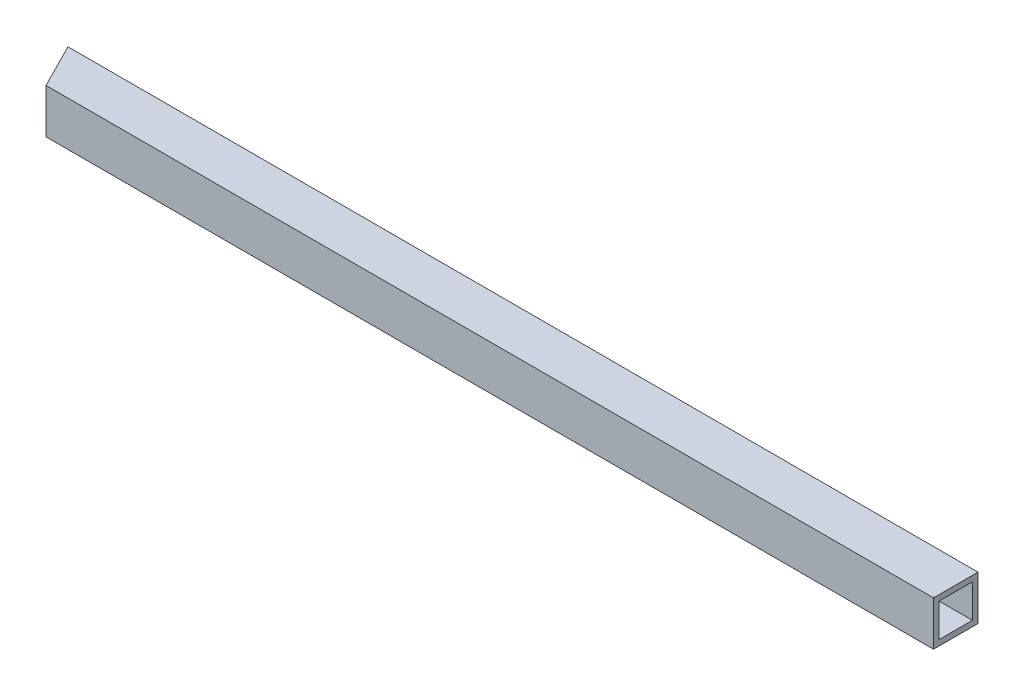
from build123d import *

# Parameters (mm, degrees)
SKETCH2_W               = 4155.694
SKETCH2_H               = 203.2
BOSS_EXTRUDE1_DEPTH     = 203.2
SKETCH3_W               = 152.4
SKETCH3_H               = 152.4
CUT_EXTRUDE1_DEPTH      = 1
CUT_EXTRUDE1_DEPTH_BACK = 4156.694
CUT_EXTRUDE2_DEPTH      = 1
CUT_EXTRUDE2_DEPTH_BACK = 204.2


with BuildPart() as part:
    # Sketch2 → Boss-Extrude1 (new body)
    with BuildSketch(Plane.XY):
        with Locations((2077.847, 101.6)):
            Rectangle(SKETCH2_W, SKETCH2_H)
    extrude(amount=BOSS_EXTRUDE1_DEPTH)

    # Sketch3 → Cut-Extrude1 (cut, two sides)
    with BuildSketch(Plane.ZY) as cut_extrude1_sk:
        with Locations((101.6, 101.6)):
            Rectangle(SKETCH3_W, SKETCH3_H)
    extrude(amount=CUT_EXTRUDE1_DEPTH, mode=Mode.SUBTRACT)
    extrude(cut_extrude1_sk.sketch, amount=-CUT_EXTRUDE1_DEPTH_BACK, mode=Mode.SUBTRACT)

    # Sketch4 → Cut-Extrude2 (cut, two sides)
    with BuildSketch(Plane(origin=(0, 203.2, 0), x_dir=(1, 0, 0), z_dir=(0, 1, 0))) as cut_extrude2_sk:
        Polygon((0, 0), (102.866376443, -203.2), (0, -203.2), align=None)
    extrude(amount=CUT_EXTRUDE2_DEPTH, mode=Mode.SUBTRACT)
    extrude(cut_extrude2_sk.sketch, amount=-CUT_EXTRUDE2_DEPTH_BACK, mode=Mode.SUBTRACT)


solid = part.part
